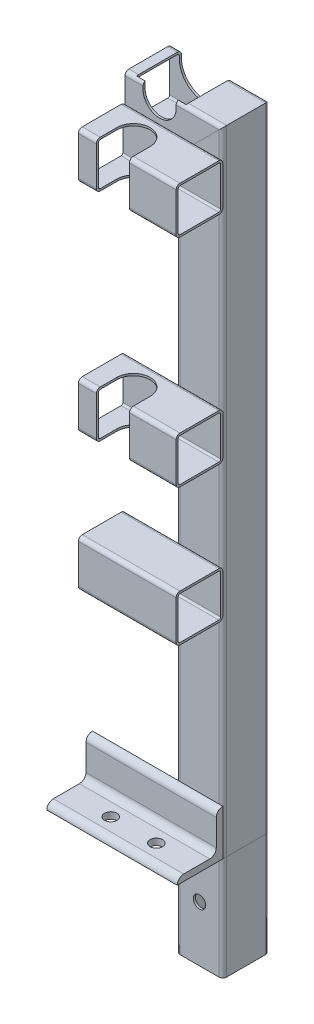
from build123d import *

# Parameters (mm, degrees)
STRUCTURAL_MEMBERMAIN_DEPTH        = 1
STRUCTURAL_MEMBERMAIN_DEPTH_BACK   = 80
STRUCTURAL_MEMBERMAIN_2_DEPTH      = 495.314422766
STRUCTURAL_MEMBERMAIN_3_DEPTH      = 83.414422766
CUT_EXTRUDETOPRAILGUIDE_DEPTH      = 538.244329891
CUT_EXTRUDETOPRAILGUIDE_DEPTH_BACK = 538.244329891
STRUCTURAL_MEMBERANGLE_DEPTH       = 100
SKETCH15_R                         = 4.7625
CUT_EXTRUDEMOUNTINGHOLES_DEPTH     = 540.545614383
CUT_EXTRUDEENLARGERAILGUIDE_START  = -17.9
CUT_EXTRUDEENLARGERAILGUIDE_DEPTH  = 34.2
STRUCTURAL_MEMBER1_DEPTH           = 75
STRUCTURAL_MEMBER1_2_DEPTH         = 75
STRUCTURAL_MEMBER1_3_DEPTH         = 75
CUT_EXTRUDE1_DEPTH                 = 594.765189279
SKETCH21_R                         = 4.7625
CUT_EXTRUDE2_DEPTH                 = 539.138179281


with BuildPart() as part:
    # Sketch11 → Structural MemberMain (new, two sides)
    with BuildSketch(Plane(origin=(210.6, 0, 0), x_dir=(-1, 0, 0), z_dir=(0, 1, 0))) as structural_membermain_sk:
        with BuildLine():
            Line((-14.9, 17.9), (14.9, 17.9))
            ThreePointArc((14.9, 17.9), (17.021320344, 17.021320344), (17.9, 14.9))
            Line((17.9, 14.9), (17.9, -14.9))
            ThreePointArc((17.9, -14.9), (17.021320344, -17.021320344), (14.9, -17.9))
            Line((14.9, -17.9), (-14.9, -17.9))
            ThreePointArc((-14.9, -17.9), (-17.021320344, -17.021320344), (-17.9, -14.9))
            Line((-17.9, -14.9), (-17.9, 14.9))
            ThreePointArc((-17.9, 14.9), (-17.021320344, 17.021320344), (-14.9, 17.9))
        make_face()
        with BuildLine():
            Line((-14.9, 16.3), (14.9, 16.3))
            ThreePointArc((14.9, 16.3), (15.889949494, 15.889949494), (16.3, 14.9))
            Line((16.3, 14.9), (16.3, -14.9))
            ThreePointArc((16.3, -14.9), (15.889949494, -15.889949494), (14.9, -16.3))
            Line((14.9, -16.3), (-14.9, -16.3))
            ThreePointArc((-14.9, -16.3), (-15.889949494, -15.889949494), (-16.3, -14.9))
            Line((-16.3, -14.9), (-16.3, 14.9))
            ThreePointArc((-16.3, 14.9), (-15.889949494, 15.889949494), (-14.9, 16.3))
        make_face(mode=Mode.SUBTRACT)
    extrude(amount=STRUCTURAL_MEMBERMAIN_DEPTH)
    extrude(structural_membermain_sk.sketch, amount=-STRUCTURAL_MEMBERMAIN_DEPTH_BACK)

    # Structural MemberMain mitre 1
    split(bisect_by=Plane(origin=(210.6, 0, 0), x_dir=(1, 0, 0), z_dir=(0, -1, 0)), keep=Keep.TOP)

    # Sketch21 → Cut-Extrude2 (cut, through all)
    with BuildSketch(Plane.XY.offset(17.9)):
        with Locations((210.6, -37.5)):
            Circle(SKETCH21_R)
    extrude(amount=-CUT_EXTRUDE2_DEPTH, mode=Mode.SUBTRACT)


with BuildPart() as body_2:
    # Sketch11 on segment 2 (carried to segment 2) → Structural MemberMain 2 (new body)
    with BuildSketch(Plane(origin=(210.6, -1, 0), x_dir=(-1, 0, 0), z_dir=(0, 1, 0))):
        with BuildLine():
            Line((-14.9, 17.9), (14.9, 17.9))
            ThreePointArc((14.9, 17.9), (17.021320344, 17.021320344), (17.9, 14.9))
            Line((17.9, 14.9), (17.9, -14.9))
            ThreePointArc((17.9, -14.9), (17.021320344, -17.021320344), (14.9, -17.9))
            Line((14.9, -17.9), (-14.9, -17.9))
            ThreePointArc((-14.9, -17.9), (-17.021320344, -17.021320344), (-17.9, -14.9))
            Line((-17.9, -14.9), (-17.9, 14.9))
            ThreePointArc((-17.9, 14.9), (-17.021320344, 17.021320344), (-14.9, 17.9))
        make_face()
        with BuildLine():
            Line((-14.9, 16.3), (14.9, 16.3))
            ThreePointArc((14.9, 16.3), (15.889949494, 15.889949494), (16.3, 14.9))
            Line((16.3, 14.9), (16.3, -14.9))
            ThreePointArc((16.3, -14.9), (15.889949494, -15.889949494), (14.9, -16.3))
            Line((14.9, -16.3), (-14.9, -16.3))
            ThreePointArc((-14.9, -16.3), (-15.889949494, -15.889949494), (-16.3, -14.9))
            Line((-16.3, -14.9), (-16.3, 14.9))
            ThreePointArc((-16.3, 14.9), (-15.889949494, 15.889949494), (-14.9, 16.3))
        make_face(mode=Mode.SUBTRACT)
    extrude(amount=STRUCTURAL_MEMBERMAIN_2_DEPTH)

    # Structural MemberMain 2 mitre 1
    split(bisect_by=Plane(origin=(210.6, 0, 0), x_dir=(-1, 0, 0), z_dir=(0, 1, 0)), keep=Keep.TOP)

    # Structural MemberMain 2 mitre 2
    split(bisect_by=Plane(origin=(210.6, 468, 0), x_dir=(0.707106781, 0.707106781, 0), z_dir=(0.707106781, -0.707106781, 0)), keep=Keep.TOP)


with BuildPart() as body_3:
    # Sketch11 on segment 3 (carried to segment 3) → Structural MemberMain 3 (new body)
    with BuildSketch(Plane(origin=(236.914422766, 468, 0), x_dir=(0, -1, 0), z_dir=(-1, 0, 0))):
        with BuildLine():
            Line((-14.9, 17.9), (14.9, 17.9))
            ThreePointArc((14.9, 17.9), (17.021320344, 17.021320344), (17.9, 14.9))
            Line((17.9, 14.9), (17.9, -14.9))
            ThreePointArc((17.9, -14.9), (17.021320344, -17.021320344), (14.9, -17.9))
            Line((14.9, -17.9), (-14.9, -17.9))
            ThreePointArc((-14.9, -17.9), (-17.021320344, -17.021320344), (-17.9, -14.9))
            Line((-17.9, -14.9), (-17.9, 14.9))
            ThreePointArc((-17.9, 14.9), (-17.021320344, 17.021320344), (-14.9, 17.9))
        make_face()
        with BuildLine():
            Line((-14.9, 16.3), (14.9, 16.3))
            ThreePointArc((14.9, 16.3), (15.889949494, 15.889949494), (16.3, 14.9))
            Line((16.3, 14.9), (16.3, -14.9))
            ThreePointArc((16.3, -14.9), (15.889949494, -15.889949494), (14.9, -16.3))
            Line((14.9, -16.3), (-14.9, -16.3))
            ThreePointArc((-14.9, -16.3), (-15.889949494, -15.889949494), (-16.3, -14.9))
            Line((-16.3, -14.9), (-16.3, 14.9))
            ThreePointArc((-16.3, 14.9), (-15.889949494, 15.889949494), (-14.9, 16.3))
        make_face(mode=Mode.SUBTRACT)
    extrude(amount=STRUCTURAL_MEMBERMAIN_3_DEPTH)

    # Structural MemberMain 3 mitre 1
    split(bisect_by=Plane(origin=(210.6, 468, 0), x_dir=(-0.707106781, -0.707106781, 0), z_dir=(-0.707106781, 0.707106781, 0)), keep=Keep.TOP)

    # Sketch12 → Cut-ExtrudeTopRailGuide (cut, two sides)
    with BuildSketch(Plane.XY) as cut_extrudetoprailguide_sk:
        with BuildLine():
            Line((167.3, 480.7), (167.3, 491.1))
            ThreePointArc((167.3, 491.1), (180, 503.8), (192.7, 491.1))
            Line((192.7, 491.1), (192.7, 480.7))
            ThreePointArc((192.7, 480.7), (180, 468), (167.3, 480.7))
        make_face()
    extrude(amount=CUT_EXTRUDETOPRAILGUIDE_DEPTH, mode=Mode.SUBTRACT)
    extrude(cut_extrudetoprailguide_sk.sketch, amount=-CUT_EXTRUDETOPRAILGUIDE_DEPTH_BACK, mode=Mode.SUBTRACT)

    # Sketch16 → Cut-ExtrudeEnlargeRailGuide (cut)
    with BuildSketch(Plane.XY.offset(CUT_EXTRUDEENLARGERAILGUIDE_START)):
        with BuildLine():
            Line((199.05, 480.7), (199.05, 491.1))
            ThreePointArc((199.05, 491.1), (180, 510.15), (160.95, 491.1))
            Line((160.95, 491.1), (160.95, 480.7))
            ThreePointArc((160.95, 480.7), (180, 461.65), (199.05, 480.7))
        make_face()
    extrude(amount=CUT_EXTRUDEENLARGERAILGUIDE_DEPTH, mode=Mode.SUBTRACT)


with BuildPart() as body_4:
    # Sketch14 → Structural MemberAngle (new body)
    with BuildSketch(Plane(origin=(128.5, 0, 17.9), x_dir=(0, 1, 0), z_dir=(1, 0, 0))):
        with BuildLine():
            Line((0, 0), (0, 35))
            ThreePointArc((0, 35), (3.535533906, 33.535533906), (5, 30))
            Line((5, 30), (5, 10))
            ThreePointArc((5, 10), (6.464466094, 6.464466094), (10, 5))
            Line((10, 5), (30, 5))
            ThreePointArc((30, 5), (33.535533906, 3.535533906), (35, 0))
            Line((35, 0), (0, 0))
        make_face()
    extrude(amount=STRUCTURAL_MEMBERANGLE_DEPTH)

    # Sketch15 → Cut-ExtrudeMountingHoles (cut, through all)
    with BuildSketch(Plane(origin=(0, 0, 0), x_dir=(1, 0, 0), z_dir=(0, 1, 0))):
        with Locations(Location((162.5, -37.9, 0), (0, 0, 90))):
            Circle(SKETCH15_R)
        with Locations(Location((197.5, -37.9, 0), (0, 0, 90))):
            Circle(SKETCH15_R)
    extrude(amount=CUT_EXTRUDEMOUNTINGHOLES_DEPTH, mode=Mode.SUBTRACT)


with BuildPart() as body_5:
    # Sketch19 → Structural Member1 (new body)
    with BuildSketch(Plane(origin=(228.5, 447.5, 35.8), x_dir=(0, -1, 0), z_dir=(-1, 0, 0))):
        with BuildLine():
            Line((-14.9, 17.9), (14.9, 17.9))
            ThreePointArc((14.9, 17.9), (17.021320344, 17.021320344), (17.9, 14.9))
            Line((17.9, 14.9), (17.9, -14.9))
            ThreePointArc((17.9, -14.9), (17.021320344, -17.021320344), (14.9, -17.9))
            Line((14.9, -17.9), (-14.9, -17.9))
            ThreePointArc((-14.9, -17.9), (-17.021320344, -17.021320344), (-17.9, -14.9))
            Line((-17.9, -14.9), (-17.9, 14.9))
            ThreePointArc((-17.9, 14.9), (-17.021320344, 17.021320344), (-14.9, 17.9))
        make_face()
        with BuildLine():
            Line((-14.9, 16.3), (14.9, 16.3))
            ThreePointArc((14.9, 16.3), (15.889949494, 15.889949494), (16.3, 14.9))
            Line((16.3, 14.9), (16.3, -14.9))
            ThreePointArc((16.3, -14.9), (15.889949494, -15.889949494), (14.9, -16.3))
            Line((14.9, -16.3), (-14.9, -16.3))
            ThreePointArc((-14.9, -16.3), (-15.889949494, -15.889949494), (-16.3, -14.9))
            Line((-16.3, -14.9), (-16.3, 14.9))
            ThreePointArc((-16.3, 14.9), (-15.889949494, 15.889949494), (-14.9, 16.3))
        make_face(mode=Mode.SUBTRACT)
    extrude(amount=STRUCTURAL_MEMBER1_DEPTH)


with BuildPart() as body_6:
    # Sketch19 on segment 2 (carried to segment 2) → Structural Member1 2 (new body)
    with BuildSketch(Plane(origin=(228.5, 281.5, 35.8), x_dir=(0, -1, 0), z_dir=(-1, 0, 0))):
        with BuildLine():
            Line((-14.9, 17.9), (14.9, 17.9))
            ThreePointArc((14.9, 17.9), (17.021320344, 17.021320344), (17.9, 14.9))
            Line((17.9, 14.9), (17.9, -14.9))
            ThreePointArc((17.9, -14.9), (17.021320344, -17.021320344), (14.9, -17.9))
            Line((14.9, -17.9), (-14.9, -17.9))
            ThreePointArc((-14.9, -17.9), (-17.021320344, -17.021320344), (-17.9, -14.9))
            Line((-17.9, -14.9), (-17.9, 14.9))
            ThreePointArc((-17.9, 14.9), (-17.021320344, 17.021320344), (-14.9, 17.9))
        make_face()
        with BuildLine():
            Line((-14.9, 16.3), (14.9, 16.3))
            ThreePointArc((14.9, 16.3), (15.889949494, 15.889949494), (16.3, 14.9))
            Line((16.3, 14.9), (16.3, -14.9))
            ThreePointArc((16.3, -14.9), (15.889949494, -15.889949494), (14.9, -16.3))
            Line((14.9, -16.3), (-14.9, -16.3))
            ThreePointArc((-14.9, -16.3), (-15.889949494, -15.889949494), (-16.3, -14.9))
            Line((-16.3, -14.9), (-16.3, 14.9))
            ThreePointArc((-16.3, 14.9), (-15.889949494, 15.889949494), (-14.9, 16.3))
        make_face(mode=Mode.SUBTRACT)
    extrude(amount=STRUCTURAL_MEMBER1_2_DEPTH)


with BuildPart() as body_7:
    # Sketch19 on segment 3 (carried to segment 3) → Structural Member1 3 (new body)
    with BuildSketch(Plane(origin=(228.5, 176.5, 35.8), x_dir=(0, -1, 0), z_dir=(-1, 0, 0))):
        with BuildLine():
            Line((-14.9, 17.9), (14.9, 17.9))
            ThreePointArc((14.9, 17.9), (17.021320344, 17.021320344), (17.9, 14.9))
            Line((17.9, 14.9), (17.9, -14.9))
            ThreePointArc((17.9, -14.9), (17.021320344, -17.021320344), (14.9, -17.9))
            Line((14.9, -17.9), (-14.9, -17.9))
            ThreePointArc((-14.9, -17.9), (-17.021320344, -17.021320344), (-17.9, -14.9))
            Line((-17.9, -14.9), (-17.9, 14.9))
            ThreePointArc((-17.9, 14.9), (-17.021320344, 17.021320344), (-14.9, 17.9))
        make_face()
        with BuildLine():
            Line((-14.9, 16.3), (14.9, 16.3))
            ThreePointArc((14.9, 16.3), (15.889949494, 15.889949494), (16.3, 14.9))
            Line((16.3, 14.9), (16.3, -14.9))
            ThreePointArc((16.3, -14.9), (15.889949494, -15.889949494), (14.9, -16.3))
            Line((14.9, -16.3), (-14.9, -16.3))
            ThreePointArc((-14.9, -16.3), (-15.889949494, -15.889949494), (-16.3, -14.9))
            Line((-16.3, -14.9), (-16.3, 14.9))
            ThreePointArc((-16.3, 14.9), (-15.889949494, 15.889949494), (-14.9, 16.3))
        make_face(mode=Mode.SUBTRACT)
    extrude(amount=STRUCTURAL_MEMBER1_3_DEPTH)


with BuildPart() as cut_extrude1_tool:
    # Sketch20 → Cut-Extrude1 (new, through all)
    with BuildSketch(Plane(origin=(0, 465.4, 0), x_dir=(1, 0, 0), z_dir=(0, 1, 0))):
        with BuildLine():
            Line((167.3, -69.5), (167.3, -37.9))
            ThreePointArc((167.3, -37.9), (180, -25.2), (192.7, -37.9))
            Line((192.7, -37.9), (192.7, -69.5))
            ThreePointArc((192.7, -69.5), (180, -82.2), (167.3, -69.5))
        make_face()
    extrude(amount=-CUT_EXTRUDE1_DEPTH)


with BuildPart() as body_5_1:
    add(body_5.part)

    # Cut-Extrude1: cut by cut_extrude1_tool
    add(cut_extrude1_tool.part, mode=Mode.SUBTRACT)


with BuildPart() as body_6_1:
    add(body_6.part)

    # Cut-Extrude1: cut by cut_extrude1_tool
    add(cut_extrude1_tool.part, mode=Mode.SUBTRACT)


solid = Compound([part.part, body_2.part, body_3.part, body_4.part, body_7.part, body_5_1.part, body_6_1.part])
